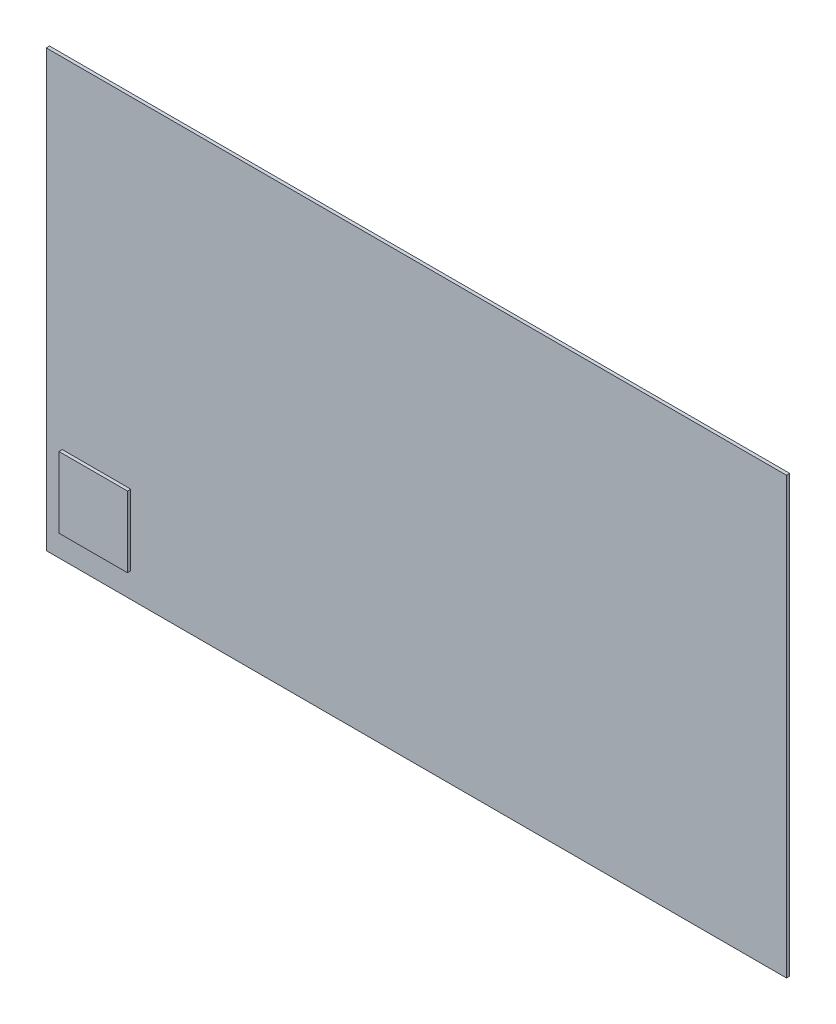
from build123d import *

# Parameters (mm, degrees)
SKETCH1_W           = 86.36
SKETCH1_H           = 50.8
BOSS_EXTRUDE1_DEPTH = 0.381
SKETCH2_W           = 7.993603734
SKETCH2_H           = 8.260057192
BOSS_EXTRUDE2_DEPTH = 0.381


with BuildPart() as part:
    # Sketch1 → Boss-Extrude1 (new body)
    with BuildSketch(Plane.XY):
        Rectangle(SKETCH1_W, SKETCH1_H)
    extrude(amount=BOSS_EXTRUDE1_DEPTH)

    # Sketch2 → Boss-Extrude2 (add)
    with BuildSketch(Plane.XY.offset(0.381)):
        with Locations((-37.321386859, -18.384844018)):
            Rectangle(SKETCH2_W, SKETCH2_H)
    extrude(amount=BOSS_EXTRUDE2_DEPTH)


solid = part.part
